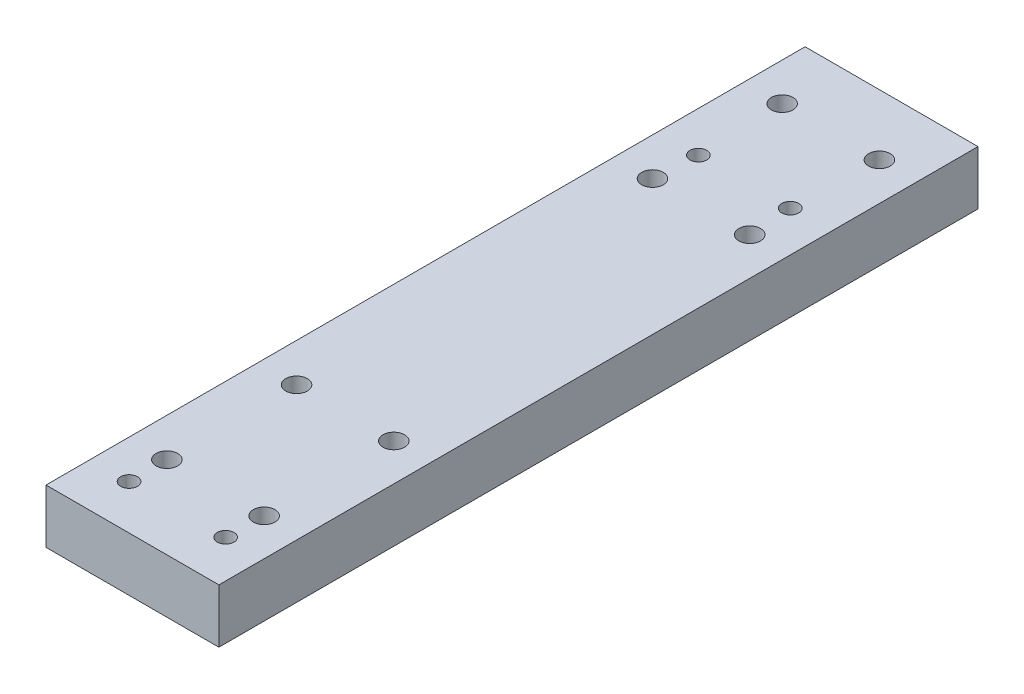
from build123d import *

# Parameters (mm, degrees)
SKETCH1_W           = 32
SKETCH1_H           = 140.5
SKETCH1_R           = 2
SKETCH1_R_2         = 1.55
BOSS_EXTRUDE1_DEPTH = 10


with BuildPart() as part:
    # Sketch1 → Boss-Extrude1 (new body)
    with BuildSketch(Plane(origin=(0, 0, 0), x_dir=(1, 0, 0), z_dir=(0, 1, 0))):
        Rectangle(SKETCH1_W, SKETCH1_H)
        with Locations((-9, 59)):
            Circle(SKETCH1_R, mode=Mode.SUBTRACT)
        with Locations((9, 59)):
            Circle(SKETCH1_R, mode=Mode.SUBTRACT)
        with Locations((-9, 35)):
            Circle(SKETCH1_R, mode=Mode.SUBTRACT)
        with Locations((9, 35)):
            Circle(SKETCH1_R, mode=Mode.SUBTRACT)
        with Locations((-8.5, 43.000105298)):
            Circle(SKETCH1_R_2, mode=Mode.SUBTRACT)
        with Locations((8.5, 43.000105298)):
            Circle(SKETCH1_R_2, mode=Mode.SUBTRACT)
        with Locations((-8.877720617, -61.999894702)):
            Circle(SKETCH1_R_2, mode=Mode.SUBTRACT)
        with Locations((9, -61.999894702)):
            Circle(SKETCH1_R_2, mode=Mode.SUBTRACT)
        with Locations((-8.877720617, -30.999894702)):
            Circle(SKETCH1_R, mode=Mode.SUBTRACT)
        with Locations((9.122279383, -30.999894702)):
            Circle(SKETCH1_R, mode=Mode.SUBTRACT)
        with Locations((9.122279383, -54.999894702)):
            Circle(SKETCH1_R, mode=Mode.SUBTRACT)
        with Locations((-8.877720617, -54.999894702)):
            Circle(SKETCH1_R, mode=Mode.SUBTRACT)
    extrude(amount=BOSS_EXTRUDE1_DEPTH)


solid = part.part
